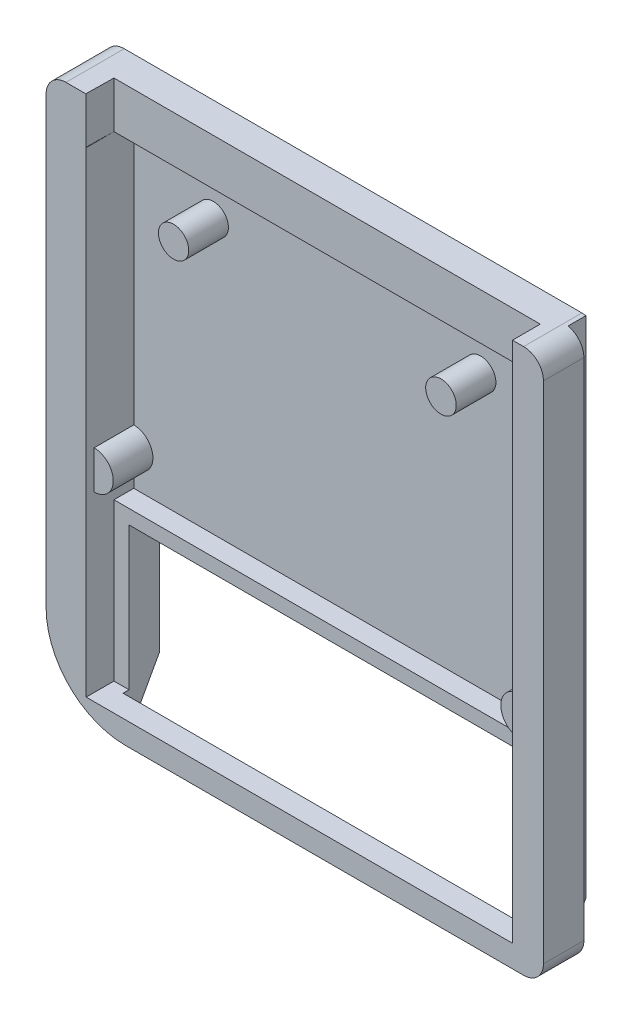
from build123d import *

# Parameters (mm, degrees)
SKETCH1_R                  = 0.970535
BOSS_EXTRUDE1_DEPTH        = 1.27
BOSS_EXTRUDE1_DEPTH_BACK   = 1.27
SKETCH1_R_2                = 0.979066
BOSS_EXTRUDE1_2_DEPTH      = 1.27
BOSS_EXTRUDE1_2_DEPTH_BACK = 1.27
SKETCH4_W                  = 26.3398
SKETCH4_H                  = 9.144
BOSS_EXTRUDE2_DEPTH        = 0.6858
SKETCH7_W                  = 27.305
SKETCH7_H                  = 30.48
BOSS_EXTRUDE10_DEPTH       = 3.048
BOSS_EXTRUDE11_DEPTH       = 2.54
BOSS_EXTRUDE12_DEPTH       = 1.27
SKETCH11_W                 = 1.143
SKETCH11_H                 = 34.8742
CUT_EXTRUDE2_DEPTH         = 1.016
CUT_EXTRUDE3_DEPTH         = 2.9718
CUT_EXTRUDE4_DEPTH         = 31.8516
SKETCH14_W                 = 2.0828
SKETCH14_H                 = 5.9944
CUT_EXTRUDE5_DEPTH         = 1.397
SKETCH15_W                 = 1.778
SKETCH15_H                 = 2.8448
CUT_EXTRUDE6_DEPTH         = 1.4986
SKETCH16_W                 = 26.3398
SKETCH16_H                 = 2.3368
CUT_EXTRUDE7_DEPTH         = 3.81


with BuildPart() as part:
    # Sketch1 → Boss-Extrude1 (new body, two sides)
    with BuildSketch(Plane.XY.offset(-1.6)) as boss_extrude1_sk:
        with Locations((121.275, -72.675)):
            Circle(SKETCH1_R)
    extrude(amount=BOSS_EXTRUDE1_DEPTH)
    extrude(boss_extrude1_sk.sketch, amount=-BOSS_EXTRUDE1_DEPTH_BACK)


with BuildPart() as body_2:
    # Sketch1 → Boss-Extrude1 2 (new body, two sides)
    with BuildSketch(Plane.XY.offset(-1.6)) as boss_extrude1_2_sk:
        with Locations((138.4, -72.7)):
            Circle(SKETCH1_R_2)
    extrude(amount=BOSS_EXTRUDE1_2_DEPTH)
    extrude(boss_extrude1_2_sk.sketch, amount=-BOSS_EXTRUDE1_2_DEPTH_BACK)


with BuildPart() as body_3:
    # Sketch4 → Boss-Extrude2 (new body)
    with BuildSketch(Plane.XY.offset(-2.87)):
        with BuildLine():
            Line((113.619599, -68.046099), (113.619599, -96.570299))
            ThreePointArc((113.619599, -96.570299), (115.107496552, -100.162401448), (118.699599, -101.650299))
            Line((118.699599, -101.650299), (144.201199, -101.650299))
            ThreePointArc((144.201199, -101.650299), (145.099224612, -101.278324612), (145.471199, -100.380299))
            Line((145.471199, -100.380299), (145.471199, -68.046099))
            ThreePointArc((145.471199, -68.046099), (145.099224612, -67.148073388), (144.201199, -66.776099))
            Line((144.201199, -66.776099), (114.889599, -66.776099))
            ThreePointArc((114.889599, -66.776099), (113.991573388, -67.148073388), (113.619599, -68.046099))
        make_face()
        with Locations((130.320099, -95.655899)):
            Rectangle(SKETCH4_W, SKETCH4_H, mode=Mode.SUBTRACT)
    extrude(amount=-BOSS_EXTRUDE2_DEPTH)

    # Sketch7 → Boss-Extrude10 (add)
    with BuildSketch(Plane.XY.offset(-2.87)):
        with BuildLine():
            Line((113.619599, -68.046099), (113.619599, -96.570299))
            ThreePointArc((113.619599, -96.570299), (115.107496552, -100.162401448), (118.699599, -101.650299))
            Line((118.699599, -101.650299), (144.201199, -101.650299))
            ThreePointArc((144.201199, -101.650299), (145.099224612, -101.278324612), (145.471199, -100.380299))
            Line((145.471199, -100.380299), (145.471199, -68.046099))
            ThreePointArc((145.471199, -68.046099), (145.099224612, -67.148073388), (144.201199, -66.776099))
            Line((144.201199, -66.776099), (114.889599, -66.776099))
            ThreePointArc((114.889599, -66.776099), (113.991573388, -67.148073388), (113.619599, -68.046099))
        make_face()
        with Locations((129.837499, -84.987899)):
            Rectangle(SKETCH7_W, SKETCH7_H, mode=Mode.SUBTRACT)
    extrude(amount=BOSS_EXTRUDE10_DEPTH)

    # Sketch8 → Boss-Extrude11 (add)
    with BuildSketch(Plane.XY.offset(-2.87)):
        with BuildLine():
            Line((116.184999, -86.652771972), (116.184999, -89.102699))
            ThreePointArc((116.184999, -89.102699), (117.409962514, -87.877735486), (116.184999, -86.652771972))
        make_face()
        with BuildLine():
            ThreePointArc((143.489913, -89.1669), (142.232854553, -87.909830419), (143.489924134, -86.652771972))
            Line((143.489924134, -86.652771972), (143.489913, -89.1669))
        make_face()
    extrude(amount=BOSS_EXTRUDE11_DEPTH)

    # Sketch10 → Boss-Extrude12 (add)
    with BuildSketch(Plane.XY.offset(-2.87)):
        Polygon((116.184519548, -90.169499), (143.489920795, -90.169499), (143.489927905, -91.083899), (117.150199, -91.083899), (117.150199, -100.227899), (116.184999, -100.227899), align=None)
    extrude(amount=BOSS_EXTRUDE12_DEPTH)

    # Sketch11 → Cut-Extrude2 (cut)
    with BuildSketch(Plane(origin=(145.471199, 0, 0), x_dir=(0, 0, -1), z_dir=(1, 0, 0))):
        with Locations((2.9843, -84.213199)):
            Rectangle(SKETCH11_W, SKETCH11_H)
    extrude(amount=-CUT_EXTRUDE2_DEPTH, mode=Mode.SUBTRACT)

    # Sketch12 → Cut-Extrude3 (cut)
    with BuildSketch(Plane.XZ.offset(69.747899)):
        Polygon((143.489920795, -1.6), (116.184999, -1.6), (116.159599, 0.178), (143.489920795, 0.178), align=None)
    extrude(amount=-CUT_EXTRUDE3_DEPTH, mode=Mode.SUBTRACT)

    # Sketch13 → Cut-Extrude4 (cut)
    with BuildSketch(Plane(origin=(145.471199, 0, 0), x_dir=(0, 0, -1), z_dir=(1, 0, 0))):
        Polygon((3.5558, -101.650299), (2.1588, -101.650299), (3.5558, -99.110299), align=None)
    extrude(amount=-CUT_EXTRUDE4_DEPTH, mode=Mode.SUBTRACT)

    # Sketch14 → Cut-Extrude5 (cut)
    with BuildSketch(Plane.ZY.offset(-113.619599)):
        with Locations((-2.5144, -98.653099)):
            Rectangle(SKETCH14_W, SKETCH14_H)
    extrude(amount=-CUT_EXTRUDE5_DEPTH, mode=Mode.SUBTRACT)

    # Sketch15 → Cut-Extrude6 (cut)
    with BuildSketch(Plane.ZY.offset(-113.619599)):
        with Locations((-2.6668, -86.740499)):
            Rectangle(SKETCH15_W, SKETCH15_H)
    extrude(amount=-CUT_EXTRUDE6_DEPTH, mode=Mode.SUBTRACT)

    # Sketch16 → Cut-Extrude7 (cut)
    with BuildSketch(Plane.XZ.offset(101.650299)):
        with Locations((130.320099, -2.3874)):
            Rectangle(SKETCH16_W, SKETCH16_H)
    extrude(amount=-CUT_EXTRUDE7_DEPTH, mode=Mode.SUBTRACT)


solid = Compound([part.part, body_2.part, body_3.part])
